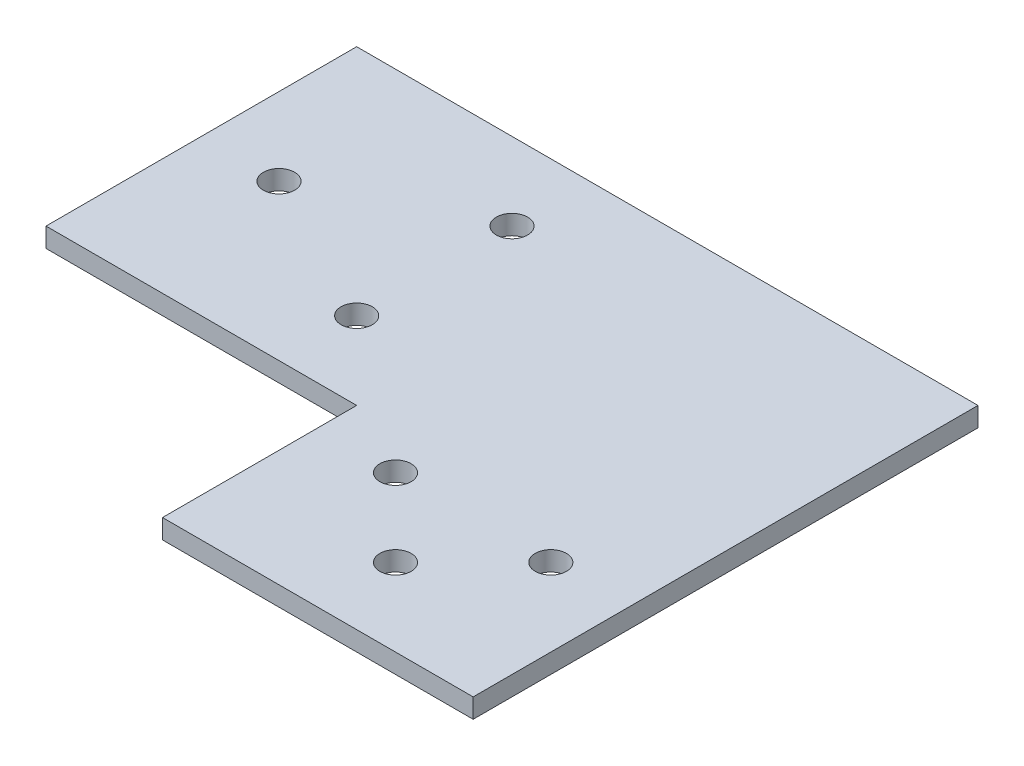
from build123d import *

# Parameters (mm, degrees)
SKETCH1_R           = 2.5527
BOSS_EXTRUDE1_DEPTH = 3.175


with BuildPart() as part:
    # Sketch1 → Boss-Extrude1 (new body)
    with BuildSketch(Plane(origin=(0, 0, 0), x_dir=(1, 0, 0), z_dir=(0, 1, 0))):
        Polygon((0, 0), (50.8, 0), (50.8, -31.75), (101.6, -31.75), (101.6, 50.8), (0, 50.8), align=None)
        with Locations((12.7, 25.4)):
            Circle(SKETCH1_R, mode=Mode.SUBTRACT)
        with Locations((38.1, 12.7)):
            Circle(SKETCH1_R, mode=Mode.SUBTRACT)
        with Locations((38.1, 38.1)):
            Circle(SKETCH1_R, mode=Mode.SUBTRACT)
        with Locations((63.5, -6.35)):
            Circle(SKETCH1_R, mode=Mode.SUBTRACT)
        with Locations((88.9, -6.35)):
            Circle(SKETCH1_R, mode=Mode.SUBTRACT)
        with Locations((76.2, -19.05)):
            Circle(SKETCH1_R, mode=Mode.SUBTRACT)
    extrude(amount=BOSS_EXTRUDE1_DEPTH)


solid = part.part
